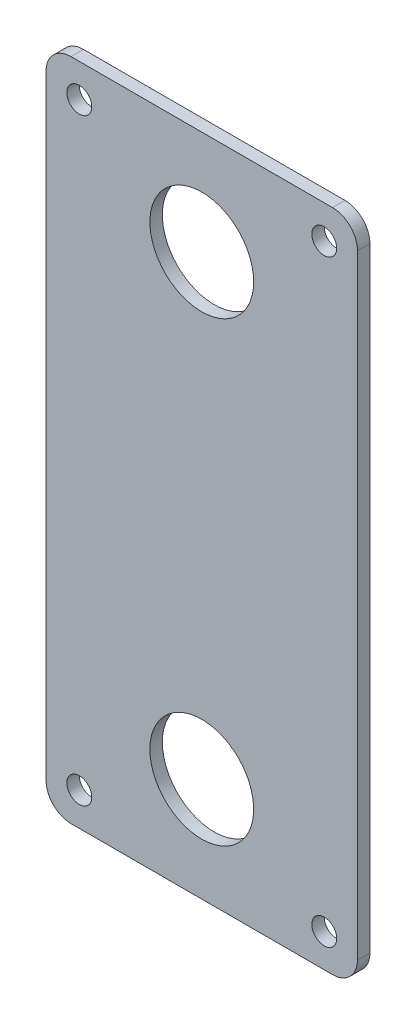
from build123d import *

# Parameters (mm, degrees)
CROQUIS1_W              = 75
CROQUIS1_H              = 160
CROQUIS1_R              = 12.5
CROQUIS1_R_2            = 3
SALIENTE_EXTRUIR1_DEPTH = 3
REDONDEO1_R             = 6


with BuildPart() as part:
    # Croquis1 → Saliente-Extruir1 (new body)
    with BuildSketch(Plane.XY):
        Rectangle(CROQUIS1_W, CROQUIS1_H)
        with Locations((0, 55)):
            Circle(CROQUIS1_R, mode=Mode.SUBTRACT)
        with Locations((0, -55)):
            Circle(CROQUIS1_R, mode=Mode.SUBTRACT)
        with Locations((-29.5, 72)):
            Circle(CROQUIS1_R_2, mode=Mode.SUBTRACT)
        with Locations((29.5, 72)):
            Circle(CROQUIS1_R_2, mode=Mode.SUBTRACT)
        with Locations((-29.5, -72)):
            Circle(CROQUIS1_R_2, mode=Mode.SUBTRACT)
        with Locations((29.5, -72)):
            Circle(CROQUIS1_R_2, mode=Mode.SUBTRACT)
    extrude(amount=SALIENTE_EXTRUIR1_DEPTH)

    # Redondeo1
    redondeo1_edges = [part.edges().sort_by_distance(p)[0] for p in [
        (-37.5, 80, 1.5),
        (37.5, 80, 1.5),
        (37.5, -80, 1.5),
        (-37.5, -80, 1.5),
    ]]
    fillet(redondeo1_edges, radius=REDONDEO1_R)


solid = part.part
